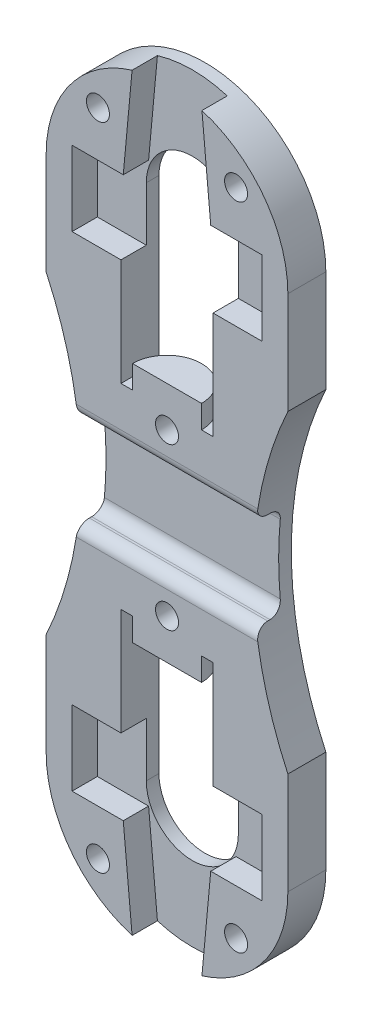
from build123d import *

# Parameters (mm, degrees)
SKETCH_1_R          = 1
EXTRUDE_1_DEPTH     = 3.3
SKETCH_2_W          = 20
SKETCH_2_H          = 8
CUT_EXTRUDE_1_DEPTH = 2.2
FILLET_1_R          = 1
EXTRUDE_2_DEPTH     = 2


with BuildPart() as part:
    # 草图1 → 凸台-拉伸1 (new body)
    with BuildSketch(Plane.XY):
        with BuildLine():
            Line((10.5, -13.638181697), (10.5, -22.5))
            ThreePointArc((10.5, -22.5), (0, -33), (-10.5, -22.5))
            Line((-10.5, -22.5), (-10.5, -13.638181697))
            ThreePointArc((-10.5, -13.638181697), (-7.5, 0), (-10.5, 13.638181697))
            Line((-10.5, 13.638181697), (-10.5, 22.5))
            ThreePointArc((-10.5, 22.5), (0, 33), (10.5, 22.5))
            Line((10.5, 22.5), (10.5, 13.638181697))
            ThreePointArc((10.5, 13.638181697), (7.5, 0), (10.5, -13.638181697))
        make_face()
        with Locations((0, 7)):
            Circle(SKETCH_1_R, mode=Mode.SUBTRACT)
        with Locations((0, -7)):
            Circle(SKETCH_1_R, mode=Mode.SUBTRACT)
        with Locations((-6, 28.25)):
            Circle(SKETCH_1_R, mode=Mode.SUBTRACT)
        with Locations((6, 28.25)):
            Circle(SKETCH_1_R, mode=Mode.SUBTRACT)
        with Locations((6, -28.25)):
            Circle(SKETCH_1_R, mode=Mode.SUBTRACT)
        with Locations((-6, -28.25)):
            Circle(SKETCH_1_R, mode=Mode.SUBTRACT)
        with BuildLine():
            Line((-4, -22.499999544), (-4, -8.5))
            Line((-4, -8.5), (4, -8.5))
            Line((4, -8.5), (4, -22.500000456))
            ThreePointArc((4, -22.500000456), (-4.56e-07, -26.5), (-4, -22.499999544))
        make_face(mode=Mode.SUBTRACT)
        with BuildLine():
            Line((-4, 22.499999544), (-4, 8.5))
            Line((-4, 8.5), (4, 8.5))
            Line((4, 8.5), (4, 22.500000456))
            ThreePointArc((4, 22.500000456), (-4.56e-07, 26.5), (-4, 22.499999544))
        make_face(mode=Mode.SUBTRACT)
    extrude(amount=EXTRUDE_1_DEPTH)

    # 草图2 → 切除-拉伸1 (cut)
    with BuildSketch(Plane.XY.offset(3.3)):
        Polygon((-3.8, 24.3), (-2.871447866, 34.3), (2.871447866, 34.3), (3.8, 24.3), (8.25, 24.3), (8.25, 17.8), (-8.25, 17.8), (-8.25, 24.3), align=None)
        Rectangle(SKETCH_2_W, SKETCH_2_H)
        Polygon((3.8, -24.3), (8.25, -24.3), (8.25, -17.8), (-8.25, -17.8), (-8.25, -24.3), (-3.8, -24.3), (-2.871447866, -34.3), (2.871447866, -34.3), align=None)
    extrude(amount=-CUT_EXTRUDE_1_DEPTH, mode=Mode.SUBTRACT)

    # 圆角1
    fillet_1_edges = [part.edges().sort_by_distance(p)[0] for p in [
        (0, -4, 1.1),
        (0, 4, 1.1),
        (0, -4, 3.3),
        (0, 4, 3.3),
    ]]
    fillet(fillet_1_edges, radius=FILLET_1_R)

    # 草图3 → 凸台-拉伸2 (add)
    with BuildSketch(Plane(origin=(0, 8.5, 0), x_dir=(1, 0, 0), z_dir=(0, 1, 0))):
        with BuildLine():
            Line((-3, -3.3), (3, -3.3))
            ThreePointArc((3, -3.3), (0, -0.3), (-3, -3.3))
        make_face()
    extrude_2 = extrude(amount=EXTRUDE_2_DEPTH)

    # 镜向1: 凸台-拉伸2 across plane
    add(extrude_2.mirror(Plane.ZX))


solid = part.part
